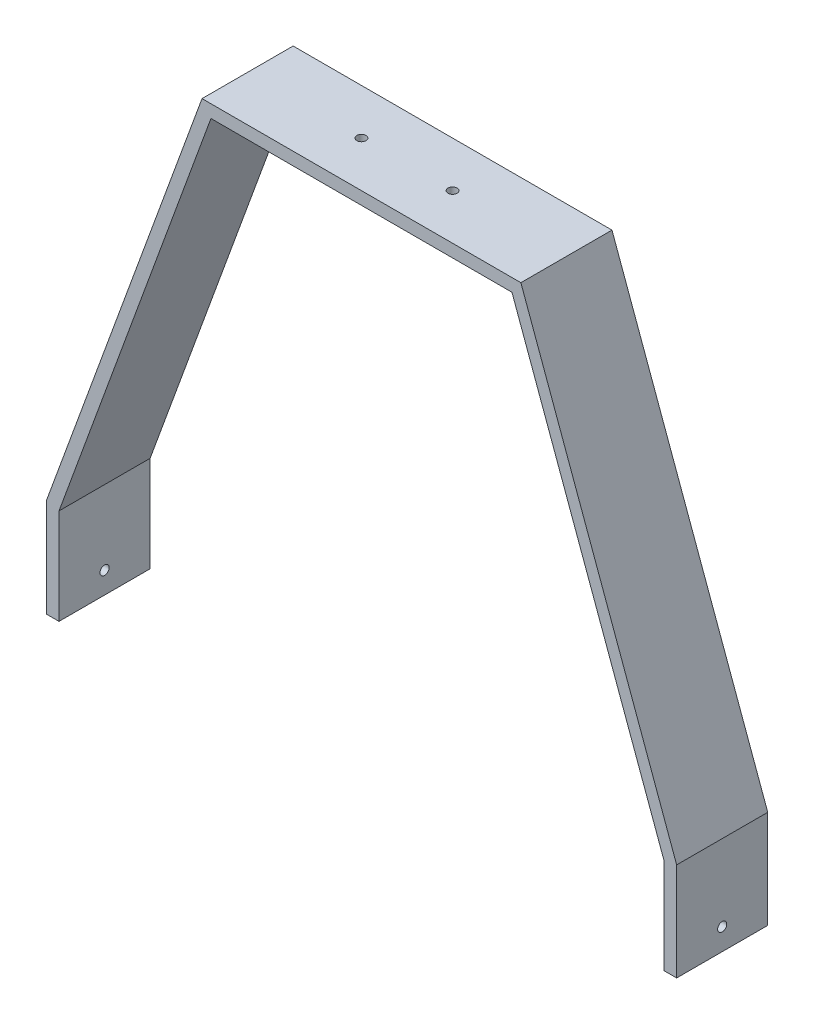
from build123d import *

# Parameters (mm, degrees)
BOSS_EXTRUDE2_DEPTH = 50
SKETCH2_R           = 2.5
CUT_EXTRUDE1_DEPTH  = 347
SKETCH3_R           = 2.5
CUT_EXTRUDE2_DEPTH  = 288.757501625


with BuildPart() as part:
    # Sketch1 → Boss-Extrude2 (new body)
    with BuildSketch(Plane.XY):
        Polygon((0, 0), (-85.5, -234), (-85.5, -287.757501625), (-78.5, -287.757501625), (-78.5, -235.238794474), (4.894944135, -7), (170.105055865, -7), (253.5, -235.238794474), (253.5, -287.757501625), (260.5, -287.757501625), (260.5, -234), (175, 0), align=None)
    extrude(amount=BOSS_EXTRUDE2_DEPTH)

    # Sketch2 → Cut-Extrude1 (cut, through all)
    with BuildSketch(Plane(origin=(260.5, 0, 0), x_dir=(0, 0, -1), z_dir=(1, 0, 0))):
        with Locations((-25, -275.891246781)):
            Circle(SKETCH2_R)
    extrude(amount=-CUT_EXTRUDE1_DEPTH, mode=Mode.SUBTRACT)

    # Sketch3 → Cut-Extrude2 (cut, through all)
    with BuildSketch(Plane(origin=(0, 0, 0), x_dir=(1, 0, 0), z_dir=(0, 1, 0))):
        with Locations((112.5, -25)):
            Circle(SKETCH3_R)
        with Locations((62.5, -25)):
            Circle(SKETCH3_R)
    extrude(amount=-CUT_EXTRUDE2_DEPTH, mode=Mode.SUBTRACT)


solid = part.part
